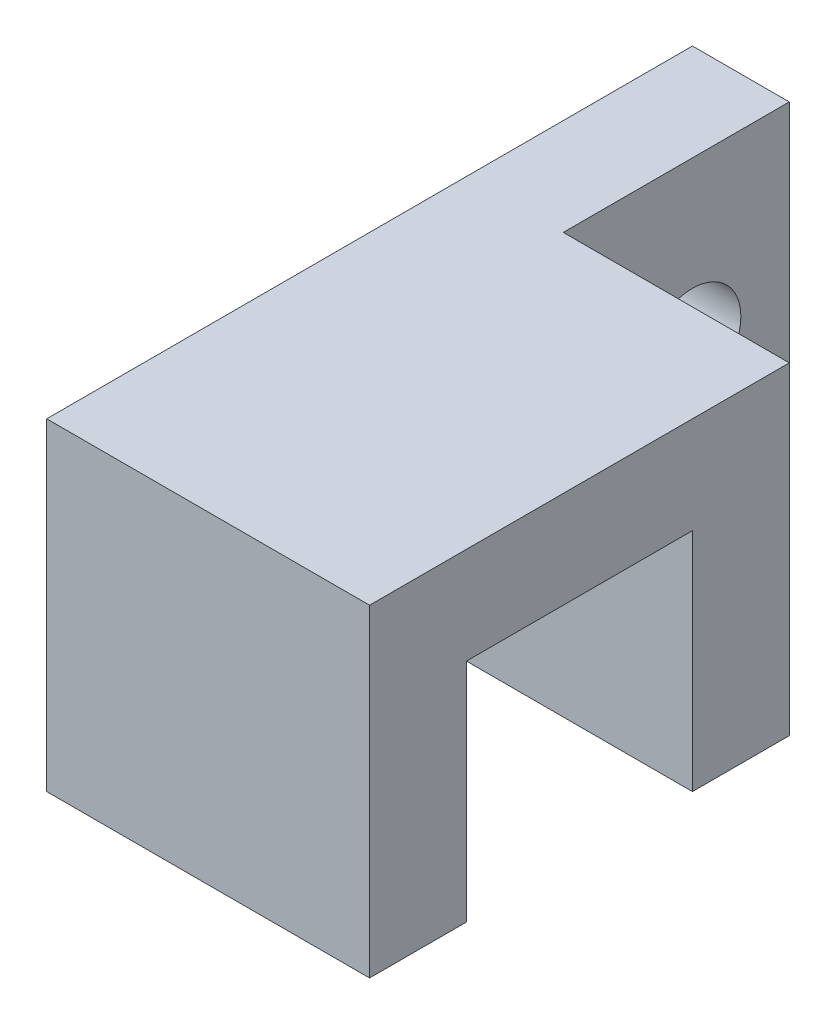
from build123d import *

# Parameters (mm, degrees)
BOSS_EXTRUDE1_DEPTH = 63.5
BOSS_EXTRUDE2_DEPTH = 63.5
SKETCH6_R           = 9.525
CUT_EXTRUDE1_DEPTH  = 20.05


with BuildPart() as part:
    # Sketch3 → Boss-Extrude1 (new body)
    with BuildSketch(Plane(origin=(0, 0, 0), x_dir=(1, 0, 0), z_dir=(0, 1, 0))):
        Polygon((0, 0), (63.5, 0), (63.5, 19.05), (19.05, 19.05), (19.05, 63.5), (0, 63.5), align=None)
    extrude(amount=BOSS_EXTRUDE1_DEPTH)

    # Sketch5 → Boss-Extrude2 (add)
    with BuildSketch(Plane(origin=(63.5, 0, 0), x_dir=(0, 0, -1), z_dir=(1, 0, 0))):
        Polygon((0, 63.5), (-63.5, 63.5), (-63.5, 0), (-44.45, 0), (-44.45, 44.45), (0, 44.45), align=None)
    extrude(amount=-BOSS_EXTRUDE2_DEPTH)

    # Sketch6 → Cut-Extrude1 (cut, through all)
    with BuildSketch(Plane(origin=(19.05, 0, 0), x_dir=(0, 0, -1), z_dir=(1, 0, 0))):
        with Locations((44.45, 31.75)):
            Circle(SKETCH6_R)
    extrude(amount=-CUT_EXTRUDE1_DEPTH, mode=Mode.SUBTRACT)


solid = part.part
